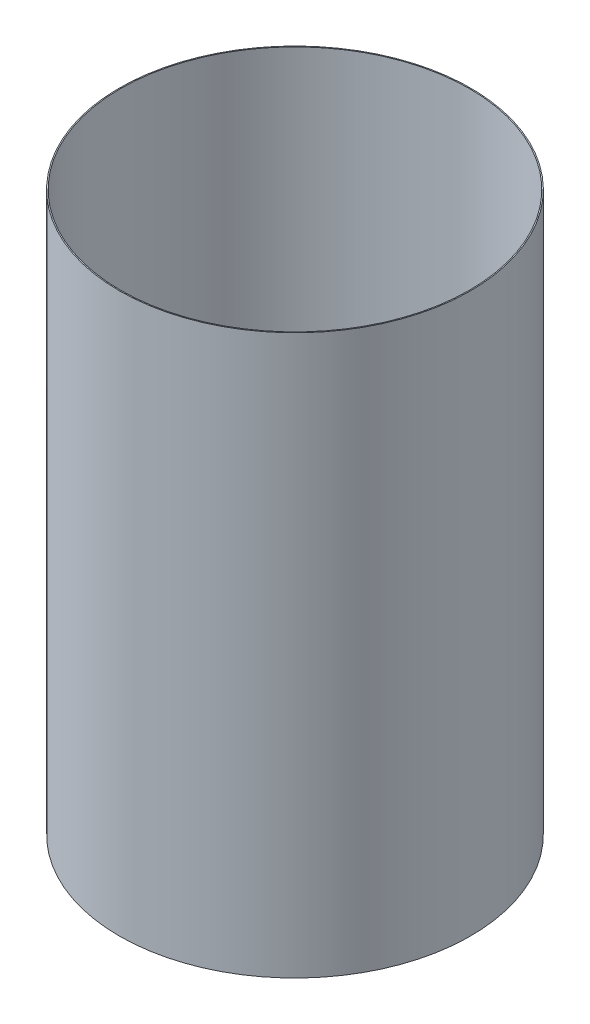
from build123d import *

# Parameters (mm, degrees)
SKETCH1_W = 0.254
SKETCH1_H = 133.35


with BuildPart() as part:
    # Sketch1 → Revolve-Thin1 (revolve)
    with BuildSketch(Plane.XY):
        with Locations((-41.783, -135.67819341)):
            Rectangle(SKETCH1_W, SKETCH1_H)
    revolve(axis=Axis((0, 55, 0), (0, -1, 0)))


solid = part.part
